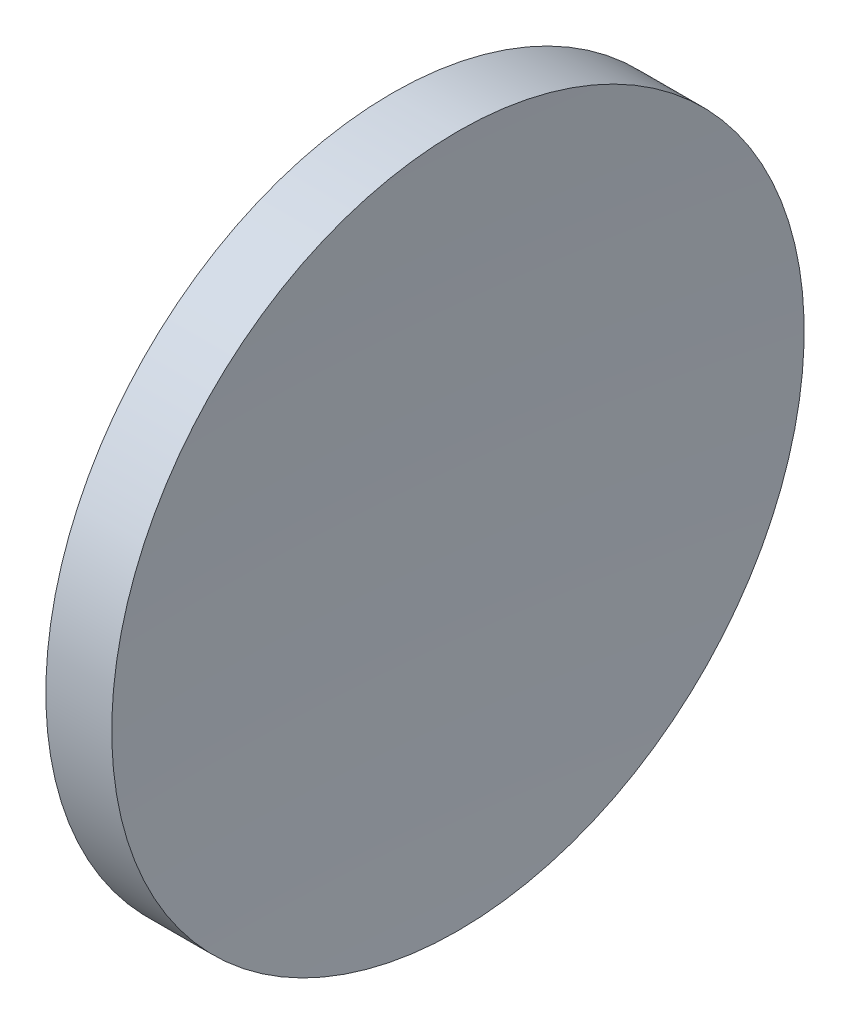
from build123d import *


with BuildPart() as part:
    # 草图1 → 旋转1 (revolve)
    with BuildSketch(Plane.XY):
        with BuildLine():
            Line((57.358190158, 32.578725913), (57.358190158, 45.078725913))
            Line((57.358190158, 45.078725913), (59.737602953, 45.078725913))
            ThreePointArc((59.737602953, 45.078725913), (59.453065194, 38.831604332), (59.358190158, 32.578725913))
            Line((59.358190158, 32.578725913), (57.358190158, 32.578725913))
        make_face()
    revolve(axis=Axis((55.007394624, 32.578725913, 0), (1, 0, 0)))


solid = part.part
